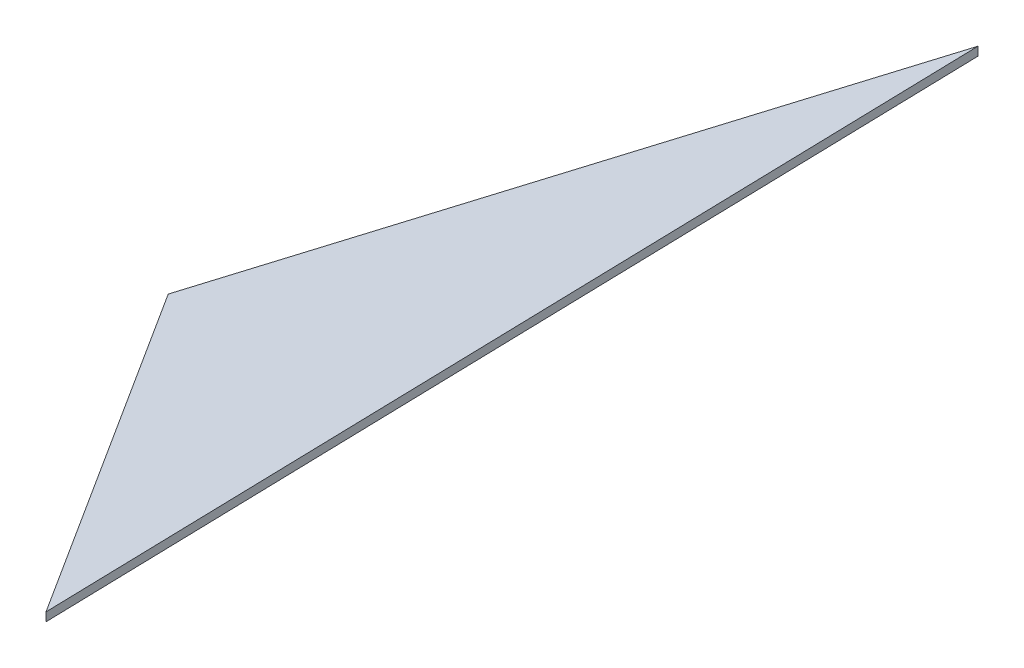
from build123d import *

# Parameters (mm, degrees)
BOSS_EXTRU_1_DEPTH = 2


with BuildPart() as part:
    # Esquisse1 → Boss.-Extru.1 (new body)
    with BuildSketch(Plane(origin=(0, 0, 0), x_dir=(1, 0, 0), z_dir=(0, 1, 0))):
        Polygon((44.024808264, 143.410928915), (0, 0), (49.556086683, -77.844834603), align=None)
    extrude(amount=BOSS_EXTRU_1_DEPTH)


solid = part.part
